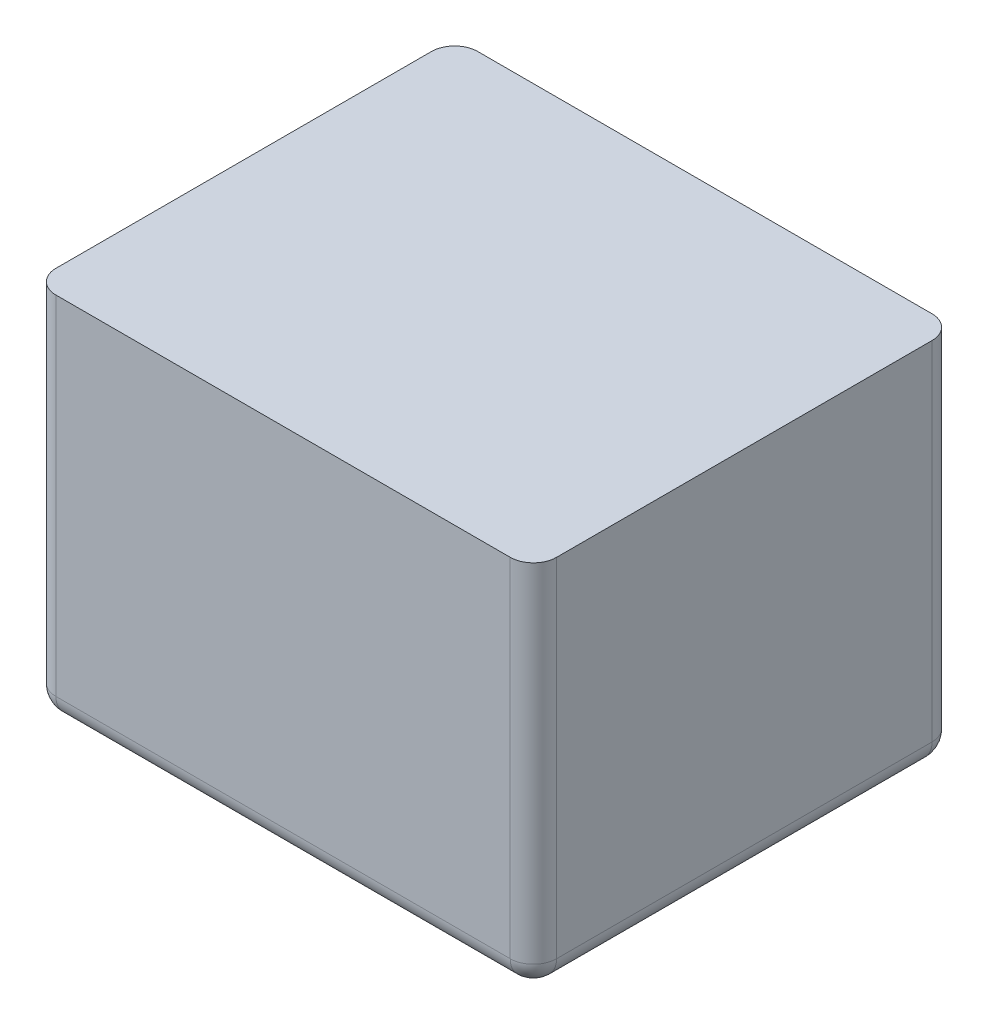
from build123d import *

# Parameters (mm, degrees)
SKIZZE1_W                       = 32.4
SKIZZE1_H                       = 27.3
AUFSATZ_LINEAR_AUSTRAGEN1_DEPTH = 24
VERRUNDUNG1_R                   = 1.5


with BuildPart() as part:
    # Skizze1 → Aufsatz-Linear austragen1 (new body)
    with BuildSketch(Plane(origin=(0, 0, 0), x_dir=(1, 0, 0), z_dir=(0, 1, 0))):
        Rectangle(SKIZZE1_W, SKIZZE1_H)
    extrude(amount=AUFSATZ_LINEAR_AUSTRAGEN1_DEPTH)

    # Verrundung1
    verrundung1_edges = [part.edges().sort_by_distance(p)[0] for p in [
        (0, 0, 13.65),
        (-16.2, 0, 0),
        (0, 0, -13.65),
        (16.2, 0, 0),
        (16.2, 12, 13.65),
        (-16.2, 12, 13.65),
        (-16.2, 12, -13.65),
        (16.2, 12, -13.65),
    ]]
    fillet(verrundung1_edges, radius=VERRUNDUNG1_R)


solid = part.part
